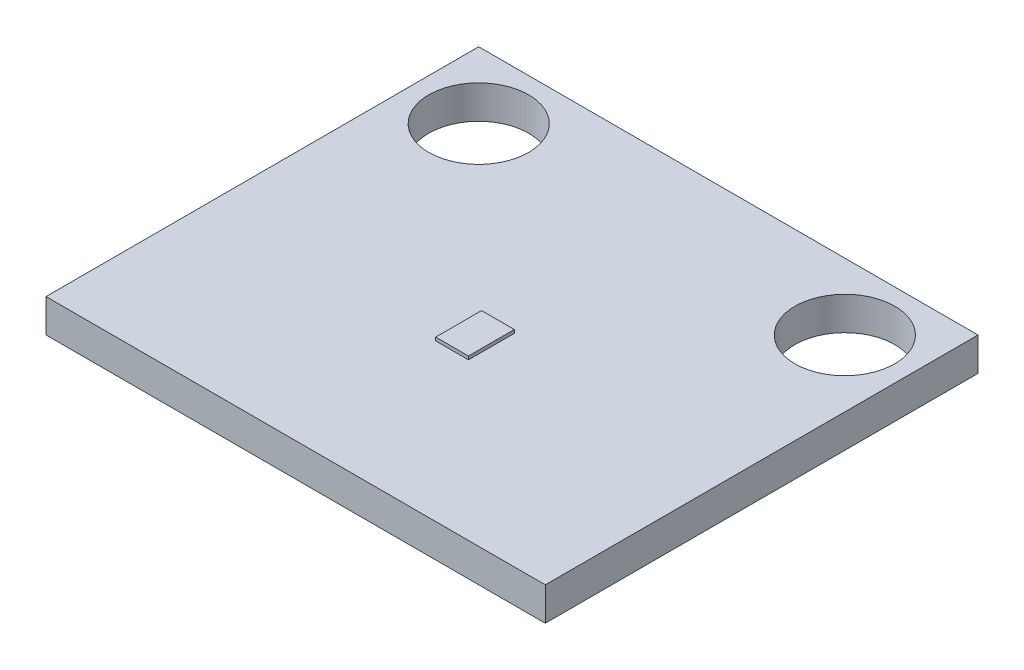
from build123d import *

# Parameters (mm, degrees)
SKETCH1_W           = 19.05
SKETCH1_H           = 16.51
BOSS_EXTRUDE1_DEPTH = 1.27
SKETCH2_R           = 1.905
CUT_EXTRUDE1_DEPTH  = 1.27
SKETCH3_W           = 1.25000004
SKETCH3_H           = 1.75
BOSS_EXTRUDE2_DEPTH = 0.127


with BuildPart() as part:
    # Sketch1 → Boss-Extrude1 (new body)
    with BuildSketch(Plane(origin=(0, 0, 0), x_dir=(1, 0, 0), z_dir=(0, 1, 0))):
        with Locations((1.883228571, -1.037771429)):
            Rectangle(SKETCH1_W, SKETCH1_H)
    extrude(amount=BOSS_EXTRUDE1_DEPTH)

    # Sketch2 → Cut-Extrude1 (cut)
    with BuildSketch(Plane(origin=(0, 1.27, 0), x_dir=(1, 0, 0), z_dir=(0, 1, 0))):
        with Locations((-5.101771429, 4.677228571)):
            Circle(SKETCH2_R)
        with Locations((8.868228571, 4.677228571)):
            Circle(SKETCH2_R)
    extrude(amount=-CUT_EXTRUDE1_DEPTH, mode=Mode.SUBTRACT)

    # Sketch3 → Boss-Extrude2 (add)
    with BuildSketch(Plane(origin=(0, 1.27, 0), x_dir=(1, 0, 0), z_dir=(0, 1, 0))):
        with Locations((1.883228571, -2.448771429)):
            Rectangle(SKETCH3_W, SKETCH3_H)
    extrude(amount=BOSS_EXTRUDE2_DEPTH)


solid = part.part
